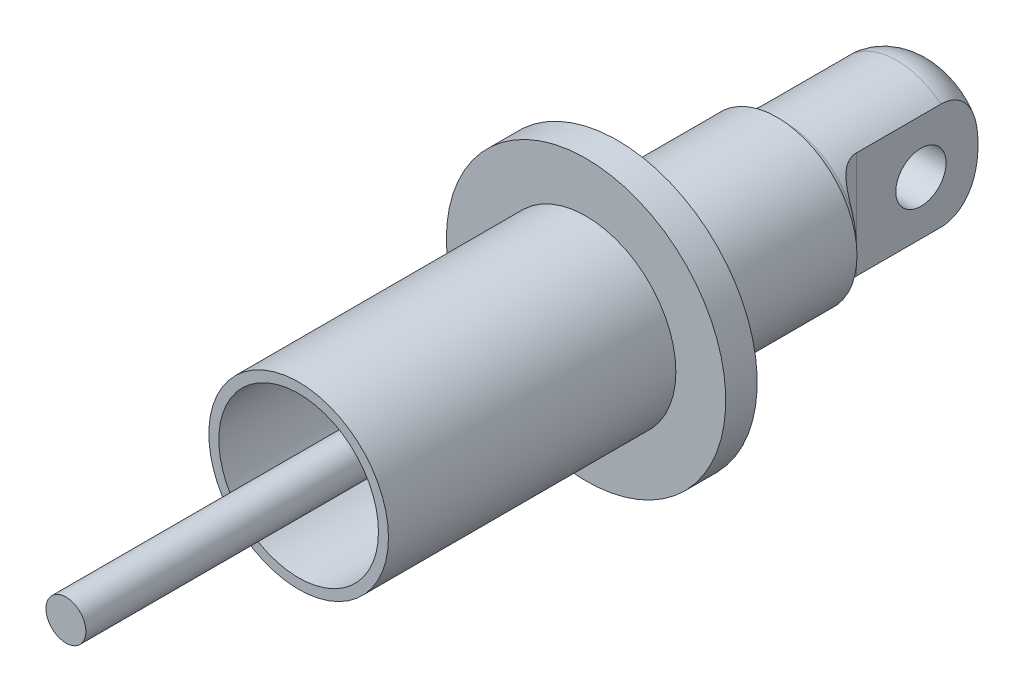
from build123d import *

# Parameters (mm, degrees)
SKETCH1_R           = 12.7
BOSS_EXTRUDE1_DEPTH = 25.4
CUT_EXTRUDE1_DEPTH  = 37.988376621
SKETCH6_R           = 4
CUT_EXTRUDE2_DEPTH  = 35.562118064
SKETCH8_R           = 14.2875
SKETCH8_R_2         = 12.7
BOSS_EXTRUDE2_DEPTH = 45.72
SKETCH9_R           = 3.175
BOSS_EXTRUDE3_DEPTH = 82.740000128


with BuildPart() as part:
    # Sketch1 → Boss-Extrude1 (new body)
    with BuildSketch(Plane.XY):
        Circle(SKETCH1_R)
    extrude(amount=BOSS_EXTRUDE1_DEPTH)

    # Sketch3 → Revolve1 (revolve)
    with BuildSketch(Plane(origin=(0, 0, 0), x_dir=(1, 0, 0), z_dir=(0, 1, 0))):
        with BuildLine():
            Line((12.5875, 0), (0, 0))
            Line((0, 0), (0, 25.4))
            Line((0, 25.4), (4.65, 25.4))
            ThreePointArc((4.65, 25.4), (9.140128061, 23.540128061), (11, 19.05))
            Line((11, 19.05), (11, 1.5875))
            ThreePointArc((11, 1.5875), (11.464967985, 0.464967985), (12.5875, 0))
        make_face()
    revolve(axis=Axis((0, 0, 0), (0, 0, -1)))

    # Sketch4 → Cut-Extrude1 (cut, through all)
    with BuildSketch(Plane(origin=(0, 11, 0), x_dir=(1, 0, 0), z_dir=(0, 1, 0))):
        with BuildLine():
            Line((-13.686249438, 25.4), (-13.686249438, 2.623707841))
            ThreePointArc((-13.686249438, 2.623707841), (-9.379043145, 1.930657253), (-7, 5.5875))
            Line((-7, 5.5875), (-7, 25.4))
            Line((-7, 25.4), (-13.686249438, 25.4))
        make_face()
        with BuildLine():
            Line((7, 25.4), (7, 5.5875))
            ThreePointArc((7, 5.5875), (9.379043145, 1.930657253), (13.686249438, 2.623707841))
            Line((13.686249438, 2.623707841), (13.686249438, 25.4))
            Line((13.686249438, 25.4), (7, 25.4))
        make_face()
    extrude(amount=-CUT_EXTRUDE1_DEPTH, mode=Mode.SUBTRACT)

    # Sketch6 → Cut-Extrude2 (cut, through all)
    with BuildSketch(Plane(origin=(7, 0, 0), x_dir=(0, 0, -1), z_dir=(1, 0, 0))):
        with Locations((15.875, 0)):
            Circle(SKETCH6_R)
    extrude(amount=-CUT_EXTRUDE2_DEPTH, mode=Mode.SUBTRACT)

    # Sketch7 → Revolve2 (revolve)
    with BuildSketch(Plane(origin=(0, 0, 0), x_dir=(1, 0, 0), z_dir=(0, 1, 0)), mode=Mode.PRIVATE) as revolve2_sk:
        with BuildLine():
            Line((12.7, -25.4), (0, -25.4))
            Line((0, -25.4), (0, -30.4))
            Line((0, -30.4), (22.225, -30.4))
            Line((22.225, -30.4), (22.225, -25.4))
            Line((22.225, -25.4), (14.2875, -25.4))
            ThreePointArc((14.2875, -25.4), (13.164967985, -24.935032015), (12.7, -23.8125))
            Line((12.7, -23.8125), (12.7, -25.4))
        make_face()
    revolve(revolve2_sk.sketch.rotate(Axis((0, 0, 25.4), (0, 0, 1)), 180), axis=Axis((0, 0, 25.4), (0, 0, 1)))

    # Sketch8 → Boss-Extrude2 (add)
    with BuildSketch(Plane.XY.offset(30.4)):
        Circle(SKETCH8_R)
        with Locations(Location((0, 0, 0), (0, 0, 180))):
            Circle(SKETCH8_R_2, mode=Mode.SUBTRACT)
    extrude(amount=BOSS_EXTRUDE2_DEPTH)

    # Sketch9 → Boss-Extrude3 (add)
    with BuildSketch(Plane.XY.offset(30.4)):
        Circle(SKETCH9_R)
    extrude(amount=BOSS_EXTRUDE3_DEPTH)


solid = part.part
